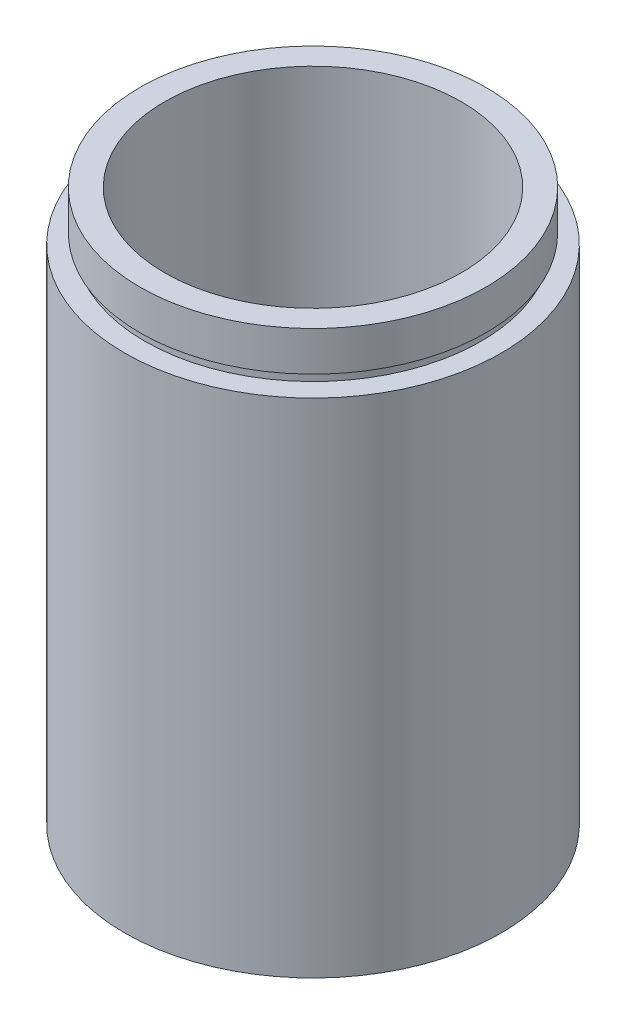
from build123d import *


with BuildPart() as part:
    # 草图1 → 旋转1 (revolve)
    with BuildSketch(Plane.XY, mode=Mode.PRIVATE) as revolve_1_sk:
        Polygon((19.05, 0), (19.05, 50.8), (17, 50.8), (17, 51.8), (17.5, 51.8), (17.5, 55.8), (15, 55.8), (15, 5.5), (17.6, 5.5), (17.6, 4.5), (17, 4.5), (17, 0), align=None)
    revolve(revolve_1_sk.sketch.rotate(Axis((0, 161.376166943, 0), (0, -1, 0)), 90), axis=Axis((0, 161.376166943, 0), (0, -1, 0)))  # turned: the seam where the file's is


solid = part.part
